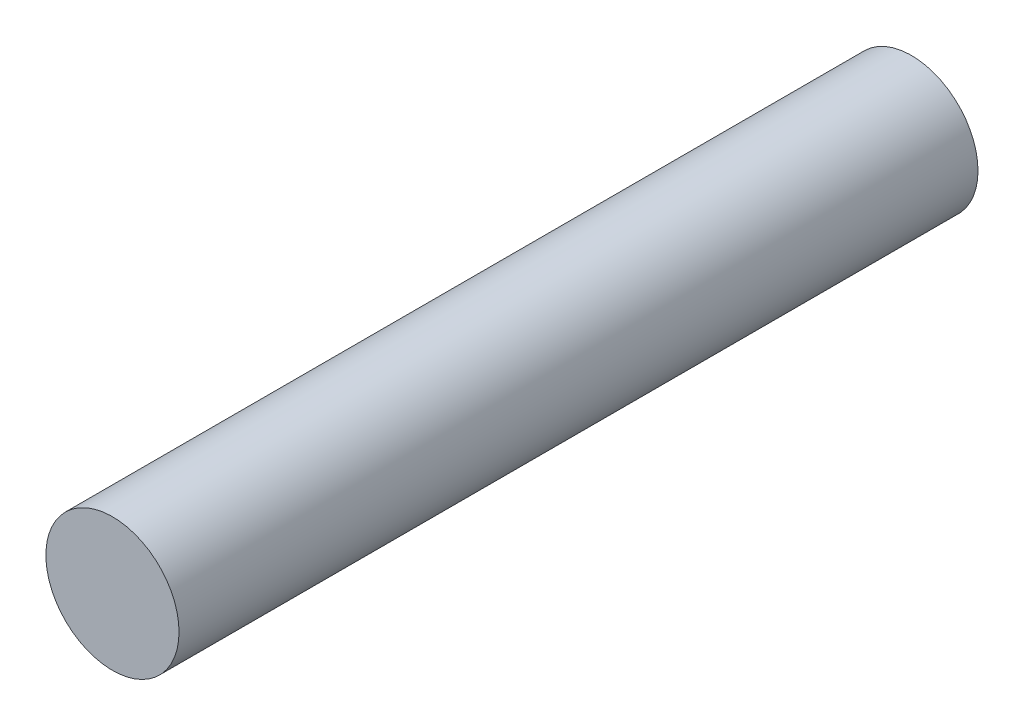
from build123d import *

# Parameters (mm, degrees)
SKETCH_1_R      = 2.5
EXTRUDE_1_DEPTH = 15


with BuildPart() as part:
    # 草圖1 → 填料-伸長1 (new body, symmetric)
    with BuildSketch(Plane.XY):
        Circle(SKETCH_1_R)
    extrude(amount=EXTRUDE_1_DEPTH, both=True)


solid = part.part
